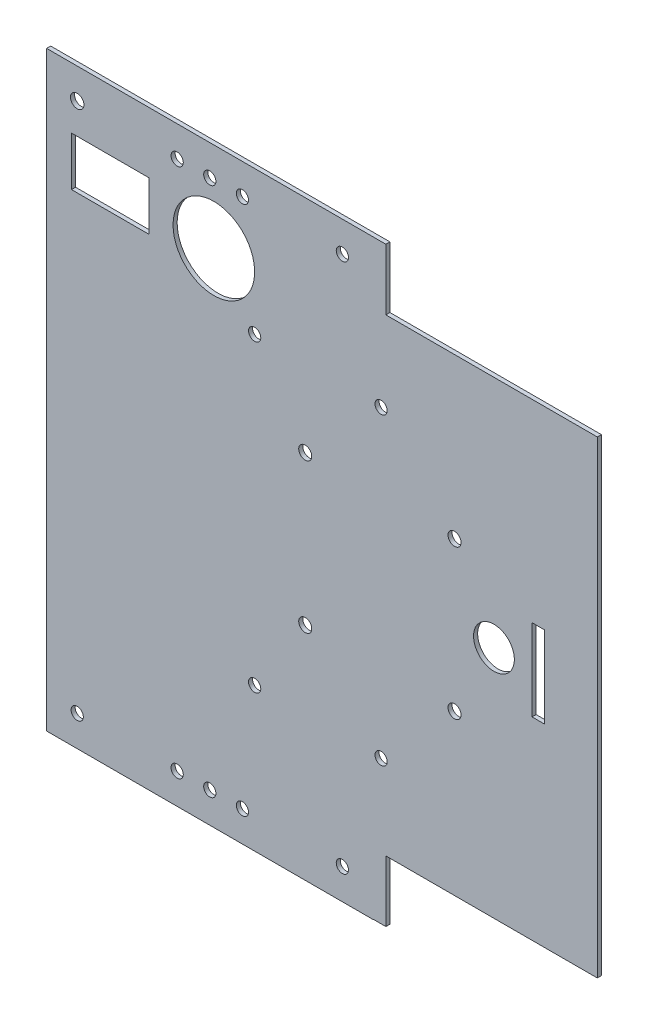
from build123d import *

# Parameters (mm, degrees)
SKETCH1_W            = 135
SKETCH1_H            = 115
BOSS_EXTRUDE1_DEPTH  = 1
SKETCH3_W            = 15
SKETCH3_H            = 15
BOSS_EXTRUDE3_DEPTH  = 1
SKETCH4_W            = 15
SKETCH4_H            = 15
BOSS_EXTRUDE4_DEPTH  = 1
SKETCH5_R            = 1.5
SKETCH5_R_2          = 1.644092979
CUT_EXTRUDE1_DEPTH   = 1
BOSS_EXTRUDE5_START  = -1
SKETCH6_W            = 50
SKETCH6_H            = 15
BOSS_EXTRUDE5_DEPTH  = 1
SKETCH7_W            = 55
SKETCH7_H            = 14.931429571
BOSS_EXTRUDE6_DEPTH  = 1
SKETCH8_W            = 55
SKETCH8_H            = 14.931429571
BOSS_EXTRUDE10_DEPTH = 1
SKETCH9_W            = 50
SKETCH9_H            = 15
BOSS_EXTRUDE11_DEPTH = 1
SKETCH10_W           = 135
SKETCH10_H           = 20
BOSS_EXTRUDE12_DEPTH = 1
SKETCH12_W           = 135
SKETCH12_H           = 20
CUT_EXTRUDE2_DEPTH   = 1
SKETCH14_W           = 51.839856939
SKETCH14_H           = 15
CUT_EXTRUDE3_DEPTH   = 1
SKETCH15_R           = 1.5
CUT_EXTRUDE5_DEPTH   = 10
SKETCH16_R           = 1.5
CUT_EXTRUDE6_DEPTH   = 10
SKETCH17_R           = 1.6
CUT_EXTRUDE9_DEPTH   = 1
SKETCH18_R           = 1.5
SKETCH18_R_2         = 10
CUT_EXTRUDE10_DEPTH  = 10
SKETCH19_R           = 10
CUT_EXTRUDE11_DEPTH  = 10
SKETCH20_W           = 19
SKETCH20_H           = 12
CUT_EXTRUDE12_DEPTH  = 10
SKETCH21_R           = 5
SKETCH21_W           = 1
SKETCH21_H           = 20
CUT_EXTRUDE13_DEPTH  = 10
SKETCH22_R           = 1.5
CUT_EXTRUDE14_DEPTH  = 10
SKETCH23_R           = 1.623611173
SKETCH23_R_2         = 1.5
SKETCH23_R_3         = 1.457682771
SKETCH23_R_4         = 10
SKETCH23_R_5         = 2.633238526
BOSS_EXTRUDE14_DEPTH = 1
SKETCH24_R           = 1.891339509
BOSS_EXTRUDE15_DEPTH = 1
SKETCH25_W           = 2
SKETCH25_H           = 20.001507343
CUT_EXTRUDE15_DEPTH  = 1
SKETCH26_R           = 1.5
CUT_EXTRUDE16_DEPTH  = 1


with BuildPart() as part:
    # Sketch1 → Boss-Extrude1 (new body)
    with BuildSketch(Plane.XY):
        with Locations((-67.5, -57.5)):
            Rectangle(SKETCH1_W, SKETCH1_H)
    extrude(amount=BOSS_EXTRUDE1_DEPTH)

    # Sketch3 → Boss-Extrude3 (add)
    with BuildSketch(Plane(origin=(0, 0, 0), x_dir=(-1, 0, 0), z_dir=(0, 0, -1))):
        with Locations((127.5, -122.5)):
            Rectangle(SKETCH3_W, SKETCH3_H)
        with Locations((127.5, 7.5)):
            Rectangle(SKETCH3_W, SKETCH3_H)
    extrude(amount=-BOSS_EXTRUDE3_DEPTH)

    # Sketch4 → Boss-Extrude4 (add)
    with BuildSketch(Plane(origin=(0, 0, 0), x_dir=(-1, 0, 0), z_dir=(0, 0, -1))):
        with Locations((62.5, -122.5)):
            Rectangle(SKETCH4_W, SKETCH4_H)
        with Locations((62.5, 7.5)):
            Rectangle(SKETCH4_W, SKETCH4_H)
    extrude(amount=-BOSS_EXTRUDE4_DEPTH)

    # Sketch5 → Cut-Extrude1 (cut)
    with BuildSketch(Plane(origin=(0, 0, 0), x_dir=(-1, 0, 0), z_dir=(0, 0, -1))):
        with Locations((62.5, -122.5)):
            Circle(SKETCH5_R)
        with Locations((127.5, -122.5)):
            Circle(SKETCH5_R)
        with Locations((62.5, 7.5)):
            Circle(SKETCH5_R)
        with Locations((127.5, 7.5)):
            Circle(SKETCH5_R_2)
    extrude(amount=-CUT_EXTRUDE1_DEPTH, mode=Mode.SUBTRACT)

    # Sketch6 → Boss-Extrude5 (add)
    with BuildSketch(Plane(origin=(0, 0, 0), x_dir=(-1, 0, 0), z_dir=(0, 0, -1)).offset(BOSS_EXTRUDE5_START)):
        with Locations((95, -122.5)):
            Rectangle(SKETCH6_W, SKETCH6_H)
    extrude(amount=BOSS_EXTRUDE5_DEPTH)

    # Sketch7 → Boss-Extrude6 (add)
    with BuildSketch(Plane(origin=(0, 0, 0), x_dir=(-1, 0, 0), z_dir=(0, 0, -1))):
        with Locations((27.5, -122.465714786)):
            Rectangle(SKETCH7_W, SKETCH7_H)
    extrude(amount=-BOSS_EXTRUDE6_DEPTH)

    # Sketch8 → Boss-Extrude10 (add)
    with BuildSketch(Plane(origin=(0, 0, 0), x_dir=(-1, 0, 0), z_dir=(0, 0, -1))):
        with Locations((27.5, 7.465714786)):
            Rectangle(SKETCH8_W, SKETCH8_H)
    extrude(amount=-BOSS_EXTRUDE10_DEPTH)

    # Sketch9 → Boss-Extrude11 (add)
    with BuildSketch(Plane(origin=(0, 0, 0), x_dir=(-1, 0, 0), z_dir=(0, 0, -1))):
        with Locations((95, 7.5)):
            Rectangle(SKETCH9_W, SKETCH9_H)
    extrude(amount=-BOSS_EXTRUDE11_DEPTH)

    # Sketch10 → Boss-Extrude12 (add)
    with BuildSketch(Plane.XY.offset(1)):
        with Locations((-67.5, 24.931429571)):
            Rectangle(SKETCH10_W, SKETCH10_H)
    extrude(amount=-BOSS_EXTRUDE12_DEPTH)

    # Sketch12 → Cut-Extrude2 (cut)
    with BuildSketch(Plane(origin=(0, 0, 0), x_dir=(-1, 0, 0), z_dir=(0, 0, -1))):
        with Locations((67.5, 24.931429571)):
            Rectangle(SKETCH12_W, SKETCH12_H)
    extrude(amount=-CUT_EXTRUDE2_DEPTH, mode=Mode.SUBTRACT)

    # Sketch14 → Cut-Extrude3 (cut)
    with BuildSketch(Plane(origin=(0, 0, 0), x_dir=(-1, 0, 0), z_dir=(0, 0, -1))):
        with Locations((25.91992847, -122.431429571)):
            Rectangle(SKETCH14_W, SKETCH14_H)
        with Locations((25.91992847, 7.431429571)):
            Rectangle(SKETCH14_W, SKETCH14_H)
    extrude(amount=-CUT_EXTRUDE3_DEPTH, mode=Mode.SUBTRACT)

    # Sketch15 → Cut-Extrude5 (cut)
    with BuildSketch(Plane(origin=(0, 0, 0), x_dir=(-1, 0, 0), z_dir=(0, 0, -1))):
        with Locations((71.839856939, -125)):
            Circle(SKETCH15_R)
        with Locations((113.463350925, -125)):
            Circle(SKETCH15_R)
        with Locations((100, -125)):
            Circle(SKETCH15_R)
        with Locations((87, -125)):
            Circle(SKETCH15_R)
        with Locations((100, 9.931429571)):
            Circle(SKETCH15_R)
        with Locations((87, 9.931429571)):
            Circle(SKETCH15_R)
        with Locations((32.99653198, -109.931429571)):
            Circle(SKETCH15_R)
        with Locations((20, -109.631168863)):
            Circle(SKETCH15_R)
        with Locations((32.99653198, -5.068570429)):
            Circle(SKETCH15_R)
        with Locations((20, -5.068570429)):
            Circle(SKETCH15_R)
    extrude(amount=-CUT_EXTRUDE5_DEPTH, mode=Mode.SUBTRACT)

    # Sketch16 → Cut-Extrude6 (cut)
    with BuildSketch(Plane(origin=(0, 0, 0), x_dir=(-1, 0, 0), z_dir=(0, 0, -1))):
        with Locations((130, -95)):
            Circle(SKETCH16_R)
        with Locations((130, -82)):
            Circle(SKETCH16_R)
        with Locations((130, -33.068570429)):
            Circle(SKETCH16_R)
        with Locations((130, -20.068570429)):
            Circle(SKETCH16_R)
    extrude(amount=-CUT_EXTRUDE6_DEPTH, mode=Mode.SUBTRACT)

    # Sketch17 → Cut-Extrude9 (cut)
    with BuildSketch(Plane(origin=(0, 0, 0), x_dir=(-1, 0, 0), z_dir=(0, 0, -1))):
        with Locations((35, -75.801429571)):
            Circle(SKETCH17_R)
        with Locations((35, -39.201429571)):
            Circle(SKETCH17_R)
        with Locations((71.6, -39.201429571)):
            Circle(SKETCH17_R)
        with Locations((71.6, -75.801429571)):
            Circle(SKETCH17_R)
    extrude(amount=-CUT_EXTRUDE9_DEPTH, mode=Mode.SUBTRACT)

    # Sketch18 → Cut-Extrude10 (cut)
    with BuildSketch(Plane(origin=(0, 0, 0), x_dir=(-1, 0, 0), z_dir=(0, 0, -1))):
        with Locations((115, -20.268570429)):
            Circle(SKETCH18_R)
        with Locations((115, -94.8)):
            Circle(SKETCH18_R)
        with Locations((84, -20.268570429)):
            Circle(SKETCH18_R)
        with Locations((84, -94.8)):
            Circle(SKETCH18_R)
        with Locations((95, -107.048943692)):
            Circle(SKETCH18_R_2)
    extrude(amount=-CUT_EXTRUDE10_DEPTH, mode=Mode.SUBTRACT)

    # Sketch19 → Cut-Extrude11 (cut)
    with BuildSketch(Plane(origin=(0, 0, 0), x_dir=(-1, 0, 0), z_dir=(0, 0, -1))):
        with Locations((94, -7.048943692)):
            Circle(SKETCH19_R)
    extrude(amount=-CUT_EXTRUDE11_DEPTH, mode=Mode.SUBTRACT)

    # Sketch20 → Cut-Extrude12 (cut)
    with BuildSketch(Plane(origin=(0, 0, 0), x_dir=(-1, 0, 0), z_dir=(0, 0, -1))):
        with Locations((119.399363066, -6)):
            Rectangle(SKETCH20_W, SKETCH20_H)
    extrude(amount=-CUT_EXTRUDE12_DEPTH, mode=Mode.SUBTRACT)

    # Sketch21 → Cut-Extrude13 (cut)
    with BuildSketch(Plane(origin=(0, 0, 0), x_dir=(-1, 0, 0), z_dir=(0, 0, -1))):
        with Locations((25.335439778, -57.496285719)):
            Circle(SKETCH21_R)
        with Locations((15.5, -57.498570429)):
            Rectangle(SKETCH21_W, SKETCH21_H)
    extrude(amount=-CUT_EXTRUDE13_DEPTH, mode=Mode.SUBTRACT)

    # Sketch22 → Cut-Extrude14 (cut)
    with BuildSketch(Plane(origin=(0, 0, 0), x_dir=(-1, 0, 0), z_dir=(0, 0, -1))):
        with Locations((53, -20.268570429)):
            Circle(SKETCH22_R)
        with Locations((53, -94.8)):
            Circle(SKETCH22_R)
    extrude(amount=-CUT_EXTRUDE14_DEPTH, mode=Mode.SUBTRACT)

    # Sketch23 → Boss-Extrude14 (add)
    with BuildSketch(Plane(origin=(0, 0, 0), x_dir=(-1, 0, 0), z_dir=(0, 0, -1))):
        with Locations((19.911217807, -5.154578825)):
            Circle(SKETCH23_R)
        with Locations((32.99653198, -5.068570429)):
            Circle(SKETCH23_R_2)
        with Locations((100, 9.931429571)):
            Circle(SKETCH23_R_2)
        with Locations((86.957682771, 9.931429571)):
            Circle(SKETCH23_R_3)
        with Locations((95, -107.048943692)):
            Circle(SKETCH23_R_4)
        with Locations((20, -109.631168863)):
            Circle(SKETCH23_R_2)
        with Locations((32.99653198, -109.931429571)):
            Circle(SKETCH23_R_2)
        with Locations((87, -125)):
            Circle(SKETCH23_R_2)
        with Locations((71.839856939, -125)):
            Circle(SKETCH23_R_5)
        with Locations((100, -125)):
            Circle(SKETCH23_R_2)
        with Locations((113.463350925, -125)):
            Circle(SKETCH23_R_2)
        with Locations((130, -20.068570429)):
            Circle(SKETCH23_R_2)
        with Locations((130, -33.068570429)):
            Circle(SKETCH23_R_2)
        with Locations((130, -82)):
            Circle(SKETCH23_R_2)
        with Locations((130, -95)):
            Circle(SKETCH23_R_2)
        with Locations((115, -20.268570429)):
            Circle(SKETCH23_R_2)
        with Locations((115, -94.8)):
            Circle(SKETCH23_R_2)
    extrude(amount=-BOSS_EXTRUDE14_DEPTH)

    # Sketch24 → Boss-Extrude15 (add)
    with BuildSketch(Plane(origin=(0, 0, 0), x_dir=(-1, 0, 0), z_dir=(0, 0, -1))):
        with Locations((86.989397584, 9.821400511)):
            Circle(SKETCH24_R)
    extrude(amount=-BOSS_EXTRUDE15_DEPTH)

    # Sketch25 → Cut-Extrude15 (cut)
    with BuildSketch(Plane(origin=(0, 0, 0), x_dir=(-1, 0, 0), z_dir=(0, 0, -1))):
        with Locations((14, -57.497816758)):
            Rectangle(SKETCH25_W, SKETCH25_H)
    extrude(amount=-CUT_EXTRUDE15_DEPTH, mode=Mode.SUBTRACT)

    # Sketch26 → Cut-Extrude16 (cut)
    with BuildSketch(Plane(origin=(0, 0, 0), x_dir=(-1, 0, 0), z_dir=(0, 0, -1))):
        with Locations((103, 7.431429571)):
            Circle(SKETCH26_R)
        with Locations((95, 7.431429571)):
            Circle(SKETCH26_R)
        with Locations((87, 7.431429571)):
            Circle(SKETCH26_R)
        with Locations((103, -122.5)):
            Circle(SKETCH26_R)
        with Locations((95, -122.5)):
            Circle(SKETCH26_R)
        with Locations((87, -122.5)):
            Circle(SKETCH26_R)
    extrude(amount=-CUT_EXTRUDE16_DEPTH, mode=Mode.SUBTRACT)


solid = part.part
